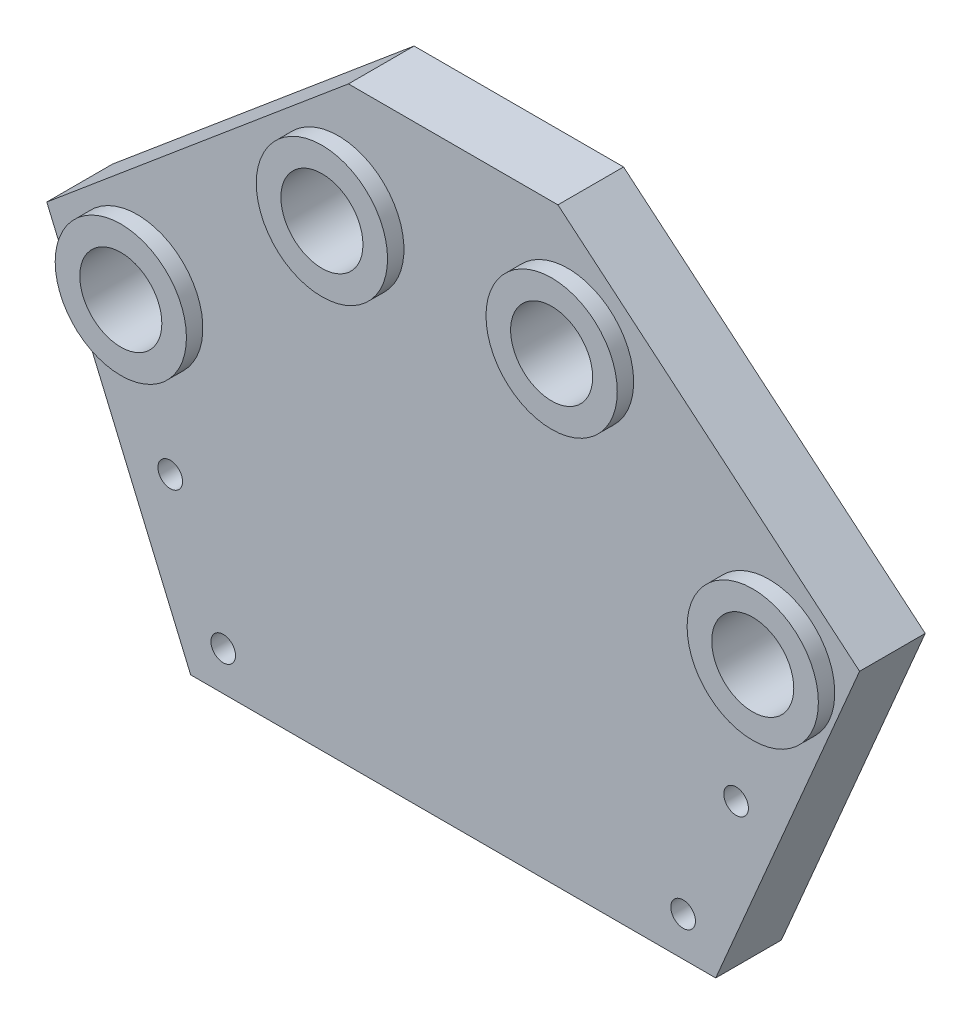
from build123d import *

# Parameters (mm, degrees)
SKETCH1_R           = 3.96875
BOSS_EXTRUDE1_DEPTH = 6.35
SKETCH2_R           = 1.190625
CUT_EXTRUDE1_DEPTH  = 6.35
SKETCH3_R           = 6.35
SKETCH3_R_2         = 3.96875
BOSS_EXTRUDE2_DEPTH = 1.5875


with BuildPart() as part:
    # Sketch1 → Boss-Extrude1 (new body)
    with BuildSketch(Plane.XY):
        Polygon((-25.4, 0), (25.4, 0), (39.320442167, 32.659792071), (10.134148885, 57.15), (-10.134148885, 57.15), (-39.320442167, 32.659792071), align=None)
        with Locations((11.1125, 45.967395581)):
            Circle(SKETCH1_R, mode=Mode.SUBTRACT)
        with Locations((-11.1125, 45.967395581)):
            Circle(SKETCH1_R, mode=Mode.SUBTRACT)
        with Locations((30.570028855, 29.640590295)):
            Circle(SKETCH1_R, mode=Mode.SUBTRACT)
        with Locations((-30.570028855, 29.640590295)):
            Circle(SKETCH1_R, mode=Mode.SUBTRACT)
    extrude(amount=BOSS_EXTRUDE1_DEPTH)

    # Sketch2 → Cut-Extrude1 (cut)
    with BuildSketch(Plane(origin=(0, 0, 0), x_dir=(-1, 0, 0), z_dir=(0, 0, -1))):
        with Locations((-27.374737278, 15.806737027)):
            Circle(SKETCH2_R)
        with Locations((-22.248493734, 3.779673069)):
            Circle(SKETCH2_R)
        with Locations((22.248493734, 3.779673069)):
            Circle(SKETCH2_R)
        with Locations((27.374737278, 15.806737027)):
            Circle(SKETCH2_R)
    extrude(amount=-CUT_EXTRUDE1_DEPTH, mode=Mode.SUBTRACT)

    # Sketch3 → Boss-Extrude2 (add)
    with BuildSketch(Plane.XY.offset(6.35)):
        with Locations((-11.1125, 45.967395581)):
            Circle(SKETCH3_R)
        with Locations((-11.1125, 45.967395581)):
            Circle(SKETCH3_R_2, mode=Mode.SUBTRACT)
        with Locations((11.1125, 45.967395581)):
            Circle(SKETCH3_R)
        with Locations((11.1125, 45.967395581)):
            Circle(SKETCH3_R_2, mode=Mode.SUBTRACT)
        with Locations((-30.570028855, 29.640590295)):
            Circle(SKETCH3_R)
        with Locations((-30.570028855, 29.640590295)):
            Circle(SKETCH3_R_2, mode=Mode.SUBTRACT)
        with Locations((30.570028855, 29.640590295)):
            Circle(SKETCH3_R)
        with Locations((30.570028855, 29.640590295)):
            Circle(SKETCH3_R_2, mode=Mode.SUBTRACT)
    extrude(amount=BOSS_EXTRUDE2_DEPTH)


solid = part.part
